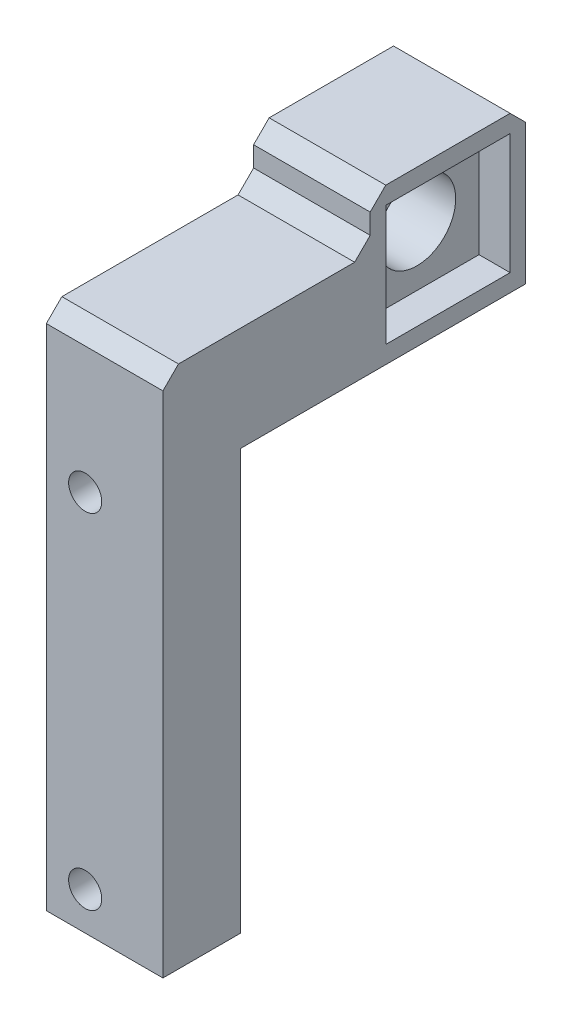
from build123d import *

# Parameters (mm, degrees)
SKETCH1_W           = 15
SKETCH1_H           = 54
SKETCH1_R           = 2.1303
BOSS_EXTRUDE1_DEPTH = 10
SKETCH2_W           = 20
SKETCH2_H           = 20
SKETCH2_R           = 5
BOSS_EXTRUDE2_DEPTH = 15
SKETCH5_W           = 26.664475469
SKETCH5_H           = 13.40994033
BOSS_EXTRUDE3_DEPTH = 15
SKETCH3_W           = 16
SKETCH3_H           = 15.5
CUT_EXTRUDE2_DEPTH  = 4
CHAMFER1_SIZE       = 2
CHAMFER2_SIZE       = 2


with BuildPart() as part:
    # Sketch1 → Boss-Extrude1 (new body)
    with BuildSketch(Plane.XY.offset(13.406799166)):
        with Locations((-42.5, 0)):
            Rectangle(SKETCH1_W, SKETCH1_H)
        with Locations((-45, -22.125)):
            Circle(SKETCH1_R, mode=Mode.SUBTRACT)
        with Locations((-45, 22.125)):
            Circle(SKETCH1_R, mode=Mode.SUBTRACT)
    extrude(amount=BOSS_EXTRUDE1_DEPTH)



with BuildPart() as body_2:
    # Sketch2 → Boss-Extrude2 (new body)
    with BuildSketch(Plane.ZY.offset(50)):
        with Locations((-13.257676303, 37)):
            Rectangle(SKETCH2_W, SKETCH2_H)
        with Locations((-13.257676303, 37)):
            Circle(SKETCH2_R, mode=Mode.SUBTRACT)
    extrude(amount=-BOSS_EXTRUDE2_DEPTH)


with BuildPart() as part_1:
    add(part.part)

    add(body_2.part)  # Boss-Extrude3 merges body 2
    # Sketch5 → Boss-Extrude3 (add)
    with BuildSketch(Plane.ZY.offset(50)):
        with Locations((10.074561432, 33.704970165)):
            Rectangle(SKETCH5_W, SKETCH5_H)
    extrude(amount=-BOSS_EXTRUDE3_DEPTH)

    # Sketch3 → Cut-Extrude2 (cut)
    with BuildSketch(Plane(origin=(-35, 0, 0), x_dir=(0, 0, -1), z_dir=(1, 0, 0))):
        with Locations((13.257676303, 37)):
            Rectangle(SKETCH3_W, SKETCH3_H)
    extrude(amount=-CUT_EXTRUDE2_DEPTH, mode=Mode.SUBTRACT)

    # Chamfer1
    chamfer1_edges = [part_1.edges().sort_by_distance(p)[0] for p in [
        (-42.5, 47, -3.257676303),
        (-42.5, 47, -23.257676303),
    ]]
    chamfer(chamfer1_edges, length=CHAMFER1_SIZE)

    # Chamfer2
    chamfer2_edges = [part_1.edges().sort_by_distance(p)[0] for p in [
        (-42.5, 40.40994033, -3.257676303),
        (-42.5, 40.40994033, 23.406799166),
    ]]
    chamfer(chamfer2_edges, length=CHAMFER2_SIZE)


solid = part_1.part
